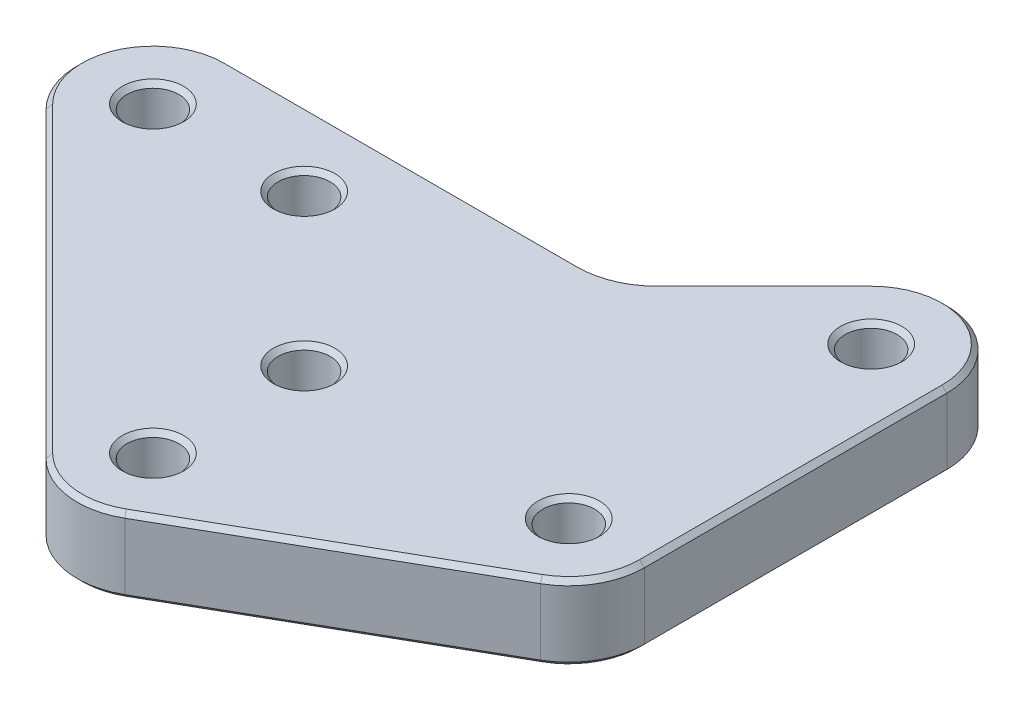
from build123d import *

# Parameters (mm, degrees)
SKETCH1_R           = 2.1828125
BOSS_EXTRUDE1_DEPTH = 6.35
CHAMFER1_SIZE       = 0.396875


with BuildPart() as part:
    # Sketch1 → Boss-Extrude1 (new body)
    with BuildSketch(Plane(origin=(0, 0, 0), x_dir=(1, 0, 0), z_dir=(0, 1, 0))):
        with BuildLine():
            Line((6.35, 25.4), (6.35, 0))
            ThreePointArc((6.35, 0), (5.492179091, -3.187235296), (3.150482259, -5.513343952))
            Line((3.150482259, -5.513343952), (-19.074517741, -18.213343952))
            ThreePointArc((-19.074517741, -18.213343952), (-23.067855509, -18.993813994), (-26.715128061, -17.190128061))
            Line((-26.715128061, -17.190128061), (-52.115128061, 8.209871939))
            ThreePointArc((-52.115128061, 8.209871939), (-53.491635031, 15.130039796), (-47.625, 19.05))
            Line((-47.625, 19.05), (-17.960512242, 19.05))
            ThreePointArc((-17.960512242, 19.05), (-15.530472447, 19.533364969), (-13.470384182, 20.909871939))
            Line((-13.470384182, 20.909871939), (-4.490128061, 29.890128061))
            ThreePointArc((-4.490128061, 29.890128061), (2.430039796, 31.266635031), (6.35, 25.4))
        make_face()
        Circle(SKETCH1_R, mode=Mode.SUBTRACT)
        with Locations((0, 25.4)):
            Circle(SKETCH1_R, mode=Mode.SUBTRACT)
        with Locations((-22.225, 0)):
            Circle(SKETCH1_R, mode=Mode.SUBTRACT)
        with Locations((-22.225, -12.7)):
            Circle(SKETCH1_R, mode=Mode.SUBTRACT)
        with Locations((-34.925, 12.7)):
            Circle(SKETCH1_R, mode=Mode.SUBTRACT)
        with Locations((-47.625, 12.7)):
            Circle(SKETCH1_R, mode=Mode.SUBTRACT)
    extrude(amount=BOSS_EXTRUDE1_DEPTH)

    # Chamfer1
    chamfer1_edges = [part.edges().sort_by_distance(p)[0] for p in [
        (-32.792756121, 0, -19.05),
        (-15.530472447, 0, -19.533364969),
        (-8.980256121, 0, -25.4),
        (2.430039796, 0, -31.266635031),
        (6.35, 0, -12.7),
        (5.492179091, 0, 3.187235296),
        (-7.962017741, 0, 11.863343952),
        (-23.067855509, 6.35, 18.993813994),
        (-23.067855509, 0, 18.993813994),
        (-39.415128061, 0, 4.490128061),
        (-53.491635031, 0, -15.130039796),
        (-7.962017741, 6.35, 11.863343952),
        (5.492179091, 6.35, 3.187235296),
        (6.35, 6.35, -12.7),
        (-2.1828125, 0, 0),
        (-2.1828125, 6.35, 0),
        (2.430039796, 6.35, -31.266635031),
        (-2.1828125, 0, -25.4),
        (-2.1828125, 6.35, -25.4),
        (-8.980256121, 6.35, -25.4),
        (-24.4078125, 0, 0),
        (-24.4078125, 6.35, 0),
        (-15.530472447, 6.35, -19.533364969),
        (-24.4078125, 0, 12.7),
        (-24.4078125, 6.35, 12.7),
        (-32.792756121, 6.35, -19.05),
        (-37.1078125, 0, -12.7),
        (-37.1078125, 6.35, -12.7),
        (-49.8078125, 0, -12.7),
        (-49.8078125, 6.35, -12.7),
        (-53.491635031, 6.35, -15.130039796),
        (-39.415128061, 6.35, 4.490128061),
    ]]
    chamfer(chamfer1_edges, length=CHAMFER1_SIZE)


solid = part.part
